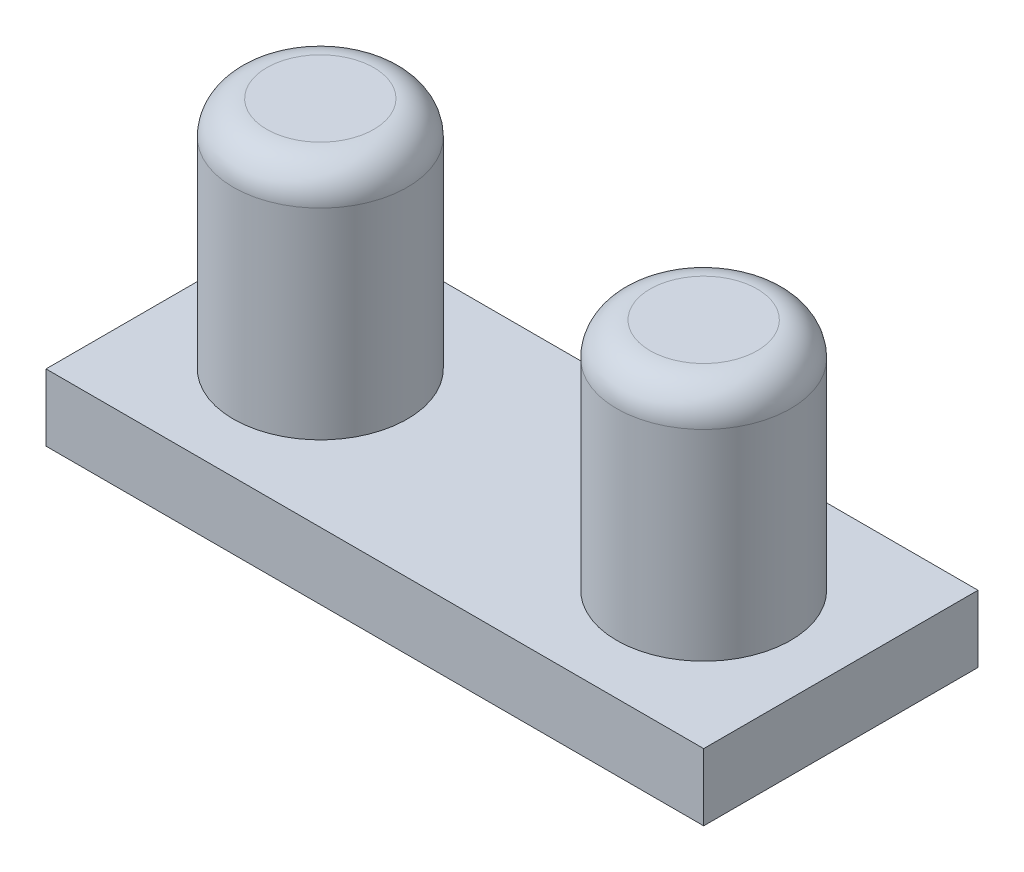
from build123d import *

# Parameters (mm, degrees)
SKETCH2_W           = 19.66
SKETCH2_H           = 8.2
BOSS_EXTRUDE1_DEPTH = 2
SKETCH3_R           = 2.6
BOSS_EXTRUDE2_DEPTH = 7
FILLET1_R           = 1


with BuildPart() as part:
    # Sketch2 → Boss-Extrude1 (new body)
    with BuildSketch(Plane(origin=(0, 0, 0), x_dir=(1, 0, 0), z_dir=(0, 1, 0))):
        Rectangle(SKETCH2_W, SKETCH2_H)
    extrude(amount=BOSS_EXTRUDE1_DEPTH)

    # Sketch3 → Boss-Extrude2 (add)
    with BuildSketch(Plane(origin=(0, 2, 0), x_dir=(1, 0, 0), z_dir=(0, 1, 0))):
        with Locations((-5.73, 0)):
            Circle(SKETCH3_R)
        with Locations((5.73, 0)):
            Circle(SKETCH3_R)
    extrude(amount=BOSS_EXTRUDE2_DEPTH)

    # Fillet1
    fillet1_edges = [part.edges().sort_by_distance(p)[0] for p in [
        (-8.33, 9, 0),
        (3.13, 9, 0),
    ]]
    fillet(fillet1_edges, radius=FILLET1_R)


solid = part.part
